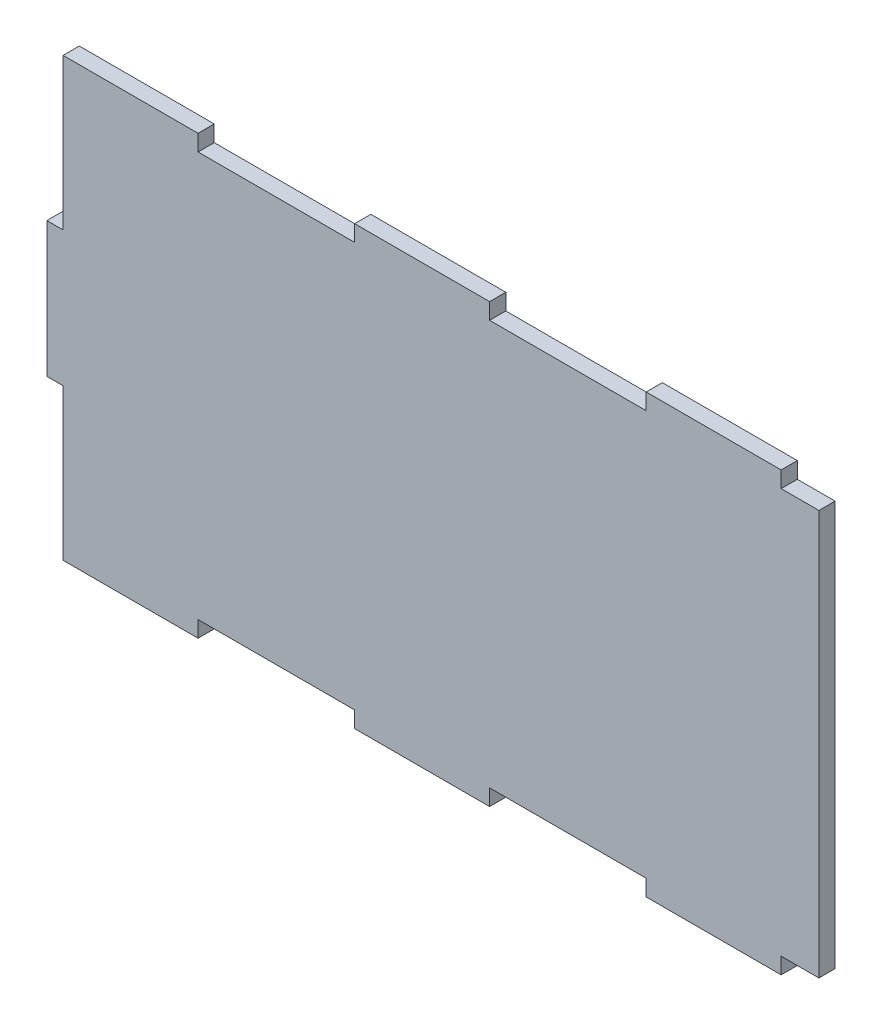
from build123d import *

# Parameters (mm, degrees)
CROQUIS1_W              = 266
CROQUIS1_H              = 150
CROQUIS1_W_2            = 50
CROQUIS1_H_2            = 6
CROQUIS1_W_3            = 6
CROQUIS1_H_3            = 50
SALIENTE_EXTRUIR1_DEPTH = 6
CROQUIS3_W              = 14
CROQUIS3_H              = 150
SALIENTE_EXTRUIR4_DEPTH = 6


with BuildPart() as part:
    # Croquis1 → Saliente-Extruir1 (new body)
    with BuildSketch(Plane.XY):
        Rectangle(CROQUIS1_W, CROQUIS1_H)
        with Locations((-108, 78)):
            Rectangle(CROQUIS1_W_2, CROQUIS1_H_2)
        with Locations((0, 78)):
            Rectangle(CROQUIS1_W_2, CROQUIS1_H_2)
        with Locations((-108, -78)):
            Rectangle(CROQUIS1_W_2, CROQUIS1_H_2)
        with Locations((0, -78)):
            Rectangle(CROQUIS1_W_2, CROQUIS1_H_2)
        with Locations((108, -78)):
            Rectangle(CROQUIS1_W_2, CROQUIS1_H_2)
        with Locations((-136, 0)):
            Rectangle(CROQUIS1_W_3, CROQUIS1_H_3)
        with Locations((108, 78)):
            Rectangle(CROQUIS1_W_2, CROQUIS1_H_2)
    extrude(amount=SALIENTE_EXTRUIR1_DEPTH)

    # Croquis3 → Saliente-Extruir4 (add)
    with BuildSketch(Plane.XY.offset(6)):
        with Locations((140, 0)):
            Rectangle(CROQUIS3_W, CROQUIS3_H)
    extrude(amount=-SALIENTE_EXTRUIR4_DEPTH)


solid = part.part
